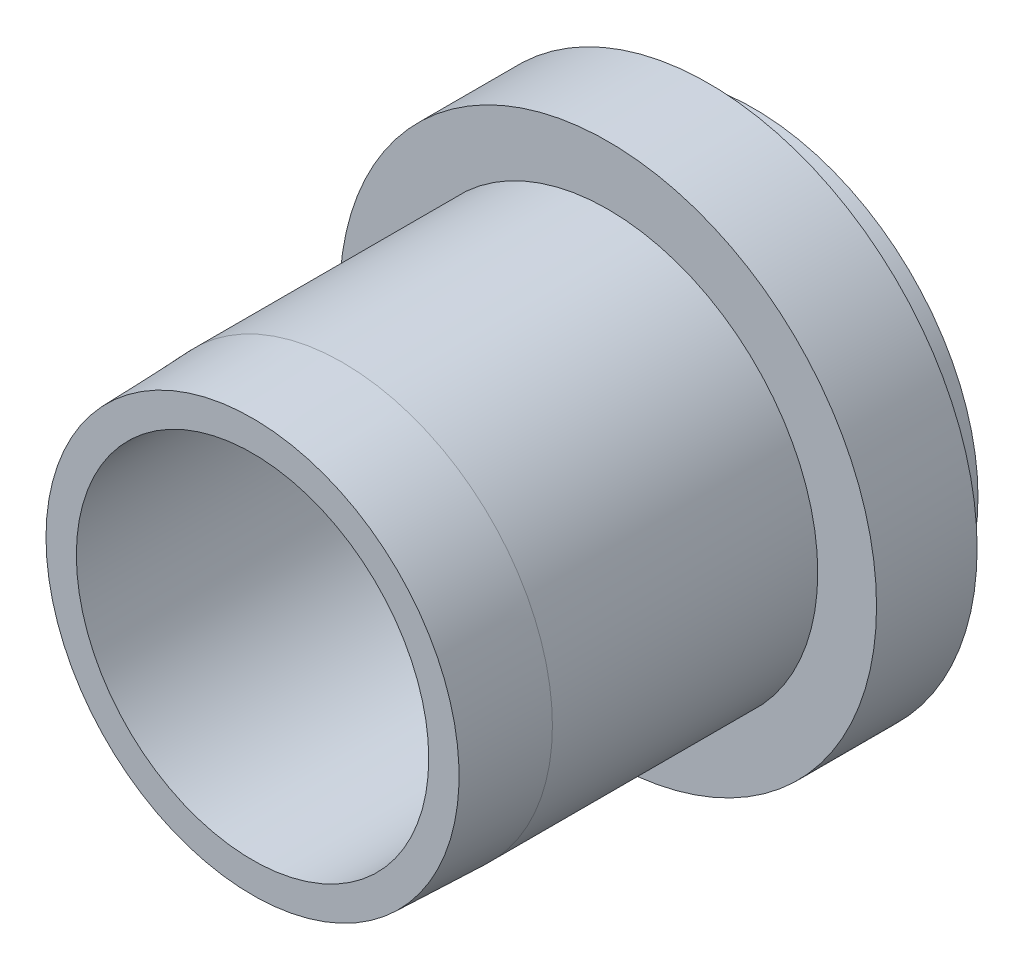
from build123d import *

# Parameters (mm, degrees)
SKETCH2_R           = 6.465
BOSS_EXTRUDE1_DEPTH = 4.2
SKETCH3_R           = 7.74
BOSS_EXTRUDE2_DEPTH = 2.9
SKETCH4_R           = 6.0452
BOSS_EXTRUDE3_DEPTH = 10.25
SKETCH5_R           = 5.08
CUT_EXTRUDE1_DEPTH  = 15.45


with BuildPart() as part:
    # Sketch2 → Boss-Extrude1 (new body)
    with BuildSketch(Plane.XY):
        Circle(SKETCH2_R)
    extrude(amount=BOSS_EXTRUDE1_DEPTH)

    # Sketch3 → Boss-Extrude2 (add)
    with BuildSketch(Plane.XY.offset(4.2)):
        Circle(SKETCH3_R)
    extrude(amount=-BOSS_EXTRUDE2_DEPTH)

    # Sketch4 → Boss-Extrude3 (add)
    with BuildSketch(Plane.XY.offset(4.2)):
        Circle(SKETCH4_R)
    extrude(amount=BOSS_EXTRUDE3_DEPTH)

    # Sketch5 → Cut-Extrude1 (cut, through all)
    with BuildSketch(Plane.XY.offset(14.45)):
        Circle(SKETCH5_R)
    extrude(amount=-CUT_EXTRUDE1_DEPTH, mode=Mode.SUBTRACT)

    # Sketch6 → Cut-Revolve1 (revolve, cut)
    with BuildSketch(Plane(origin=(0, 0, 0), x_dir=(0, 0, -1), z_dir=(1, 0, 0))):
        Polygon((-14.45, 5.954405999), (-11.85, 6.0452), (-14.45, 6.0452), align=None)
    revolve(axis=Axis((0, 0, 0), (0, 0, 1)), mode=Mode.SUBTRACT)


solid = part.part
